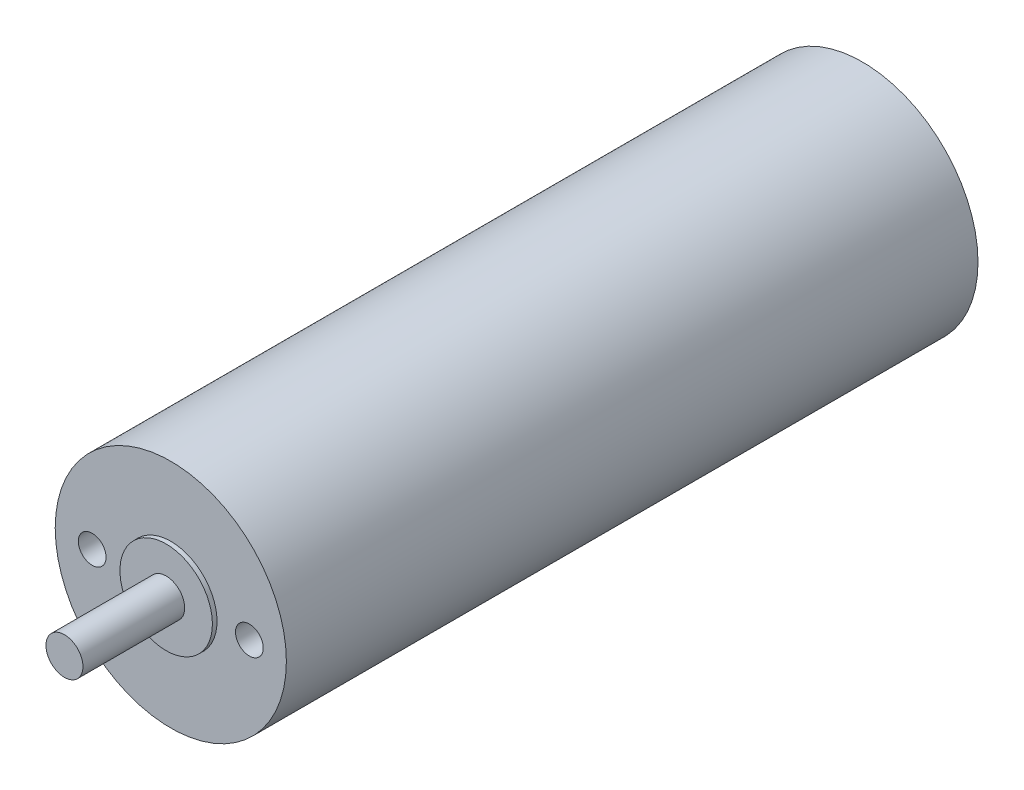
from build123d import *

# Parameters (mm, degrees)
SKETCH3_R           = 12.5
BOSS_EXTRUDE1_DEPTH = 74.8
SKETCH4_R           = 5
BOSS_EXTRUDE2_DEPTH = 0.5
SKETCH5_R           = 2
BOSS_EXTRUDE3_DEPTH = 11
SKETCH6_R           = 1.5
CUT_EXTRUDE1_DEPTH  = 4


with BuildPart() as part:
    # Sketch3 → Boss-Extrude1 (new body)
    with BuildSketch(Plane.XY):
        Circle(SKETCH3_R)
    extrude(amount=BOSS_EXTRUDE1_DEPTH)

    # Sketch4 → Boss-Extrude2 (add)
    with BuildSketch(Plane.XY.offset(74.8)):
        Circle(SKETCH4_R)
    extrude(amount=BOSS_EXTRUDE2_DEPTH)

    # Sketch5 → Boss-Extrude3 (add)
    with BuildSketch(Plane.XY.offset(75.3)):
        Circle(SKETCH5_R)
    extrude(amount=BOSS_EXTRUDE3_DEPTH)

    # Sketch6 → Cut-Extrude1 (cut)
    with BuildSketch(Plane.XY.offset(74.8)):
        with Locations((-8.5, 0)):
            Circle(SKETCH6_R)
        with Locations((8.5, 0)):
            Circle(SKETCH6_R)
    extrude(amount=-CUT_EXTRUDE1_DEPTH, mode=Mode.SUBTRACT)


solid = part.part
